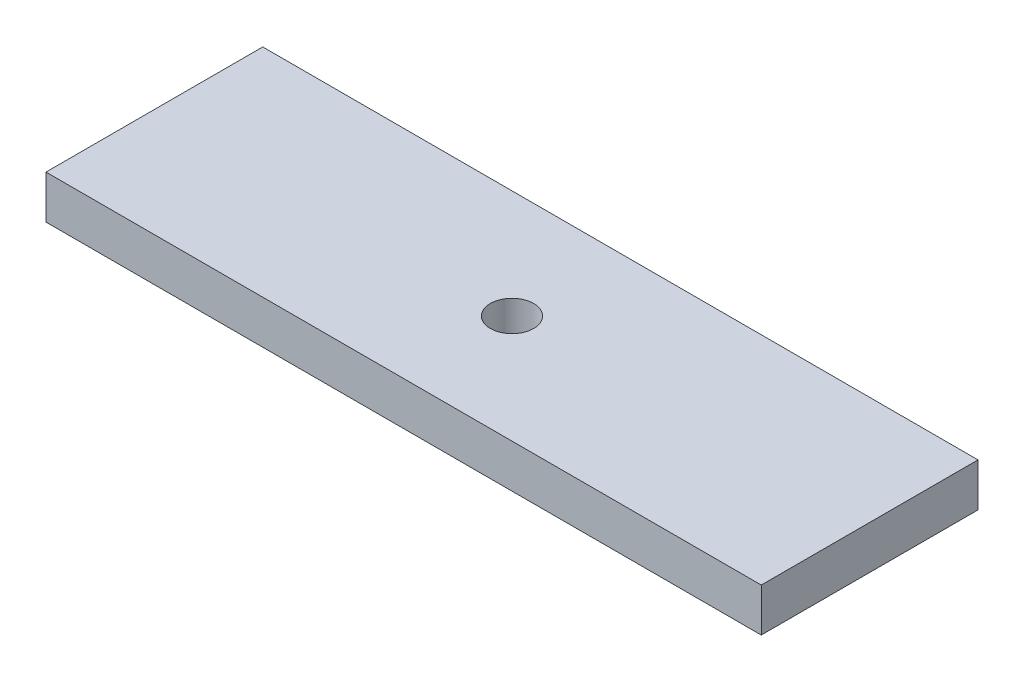
from build123d import *

# Parameters (mm, degrees)
SKETCH1_W           = 66
SKETCH1_H           = 20
BOSS_EXTRUDE1_DEPTH = 4
SKETCH2_R           = 2
CUT_EXTRUDE1_DEPTH  = 5


with BuildPart() as part:
    # Sketch1 → Boss-Extrude1 (new body)
    with BuildSketch(Plane(origin=(0, 0, 0), x_dir=(1, 0, 0), z_dir=(0, 1, 0))):
        with Locations((33, -10)):
            Rectangle(SKETCH1_W, SKETCH1_H)
    extrude(amount=BOSS_EXTRUDE1_DEPTH)

    # Sketch2 → Cut-Extrude1 (cut, through all)
    with BuildSketch(Plane(origin=(0, 4, 0), x_dir=(1, 0, 0), z_dir=(0, 1, 0))):
        with Locations((33, -10)):
            Circle(SKETCH2_R)
    extrude(amount=-CUT_EXTRUDE1_DEPTH, mode=Mode.SUBTRACT)


solid = part.part
